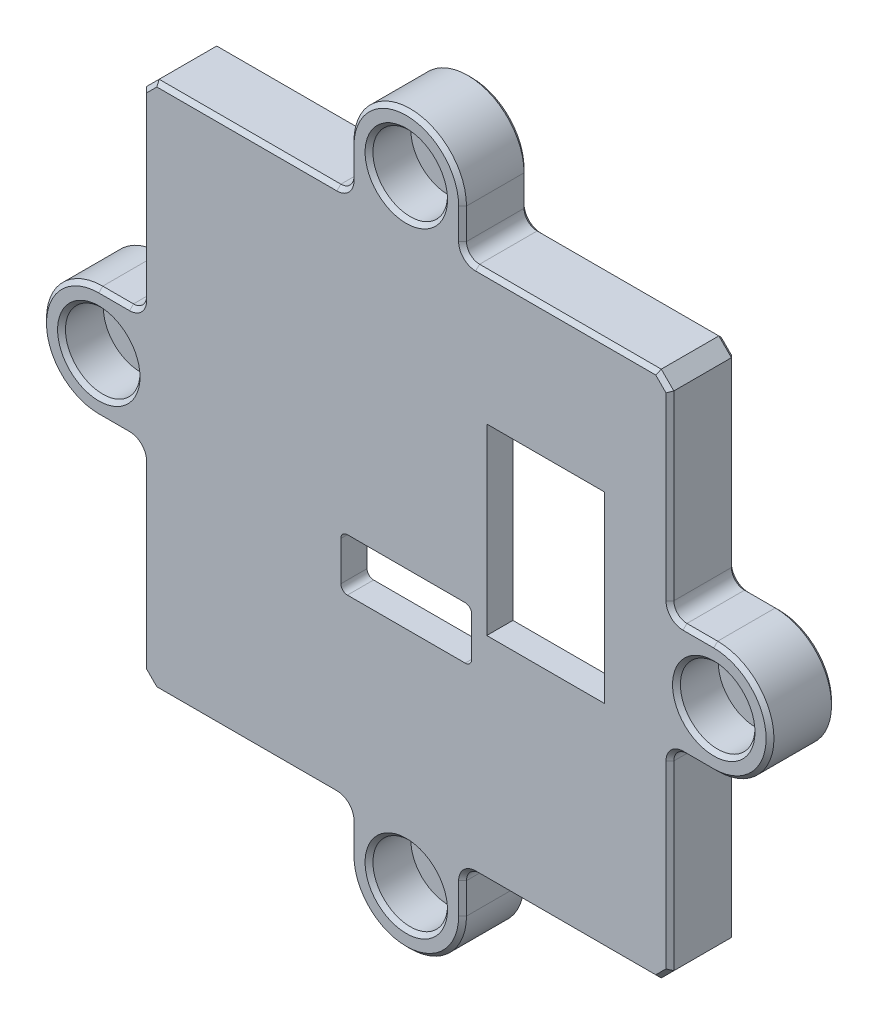
from build123d import *

# Parameters (mm, degrees)
SKETCH1_R           = 1.75
SKETCH1_W           = 9
SKETCH1_H           = 14
SKETCH1_W_2         = 10
SKETCH1_H_2         = 4
BOSS_EXTRUDE1_DEPTH = 5
FILLET3_R           = 0.5
SKETCH2_R           = 2.85
CUT_EXTRUDE1_DEPTH  = 3.2
SKETCH3_R           = 2.407181936
SKETCH3_R_2         = 2.340327513
SKETCH3_R_3         = 2.41187395
SKETCH3_R_4         = 2.413205516
BOSS_EXTRUDE2_DEPTH = 0.2
SKETCH4_W           = 35
SKETCH4_H           = 35
CUT_EXTRUDE2_DEPTH  = 4
SKETCH5_W           = 9
SKETCH5_H           = 14
BOSS_EXTRUDE3_DEPTH = 1
FILLET2_R           = 1
FILLET1_R           = 2
CHAMFER1_SIZE       = 0.3


with BuildPart() as part:
    # Sketch1 → Boss-Extrude1 (new body)
    with BuildSketch(Plane.XY):
        with BuildLine():
            Line((19.188334778, 20.15), (20.15, 19.188334778))
            Line((20.15, 19.188334778), (20.15, 4.3))
            Line((20.15, 4.3), (23.5, 4.3))
            ThreePointArc((23.5, 4.3), (27.8, 0), (23.5, -4.3))
            Line((23.5, -4.3), (20.15, -4.3))
            Line((20.15, -4.3), (20.15, -19.188334778))
            Line((20.15, -19.188334778), (19.188334778, -20.15))
            Line((19.188334778, -20.15), (4.3, -20.15))
            Line((4.3, -20.15), (4.3, -23.5))
            ThreePointArc((4.3, -23.5), (0, -27.8), (-4.3, -23.5))
            Line((-4.3, -23.5), (-4.3, -20.15))
            Line((-4.3, -20.15), (-19.188334778, -20.15))
            Line((-19.188334778, -20.15), (-20.15, -19.188334778))
            Line((-20.15, -19.188334778), (-20.15, -4.3))
            Line((-20.15, -4.3), (-23.5, -4.3))
            ThreePointArc((-23.5, -4.3), (-27.8, 0), (-23.5, 4.3))
            Line((-23.5, 4.3), (-20.15, 4.3))
            Line((-20.15, 4.3), (-20.15, 19.188334778))
            Line((-20.15, 19.188334778), (-19.188334778, 20.15))
            Line((-19.188334778, 20.15), (-4.3, 20.15))
            Line((-4.3, 20.15), (-4.3, 23.5))
            ThreePointArc((-4.3, 23.5), (0, 27.8), (4.3, 23.5))
            Line((4.3, 23.5), (4.3, 20.15))
            Line((4.3, 20.15), (19.188334778, 20.15))
        make_face()
        with Locations((0, 23.5)):
            Circle(SKETCH1_R, mode=Mode.SUBTRACT)
        with Locations((23.5, 0)):
            Circle(SKETCH1_R, mode=Mode.SUBTRACT)
        with Locations((0, -23.5)):
            Circle(SKETCH1_R, mode=Mode.SUBTRACT)
        with Locations((-23.5, 0)):
            Circle(SKETCH1_R, mode=Mode.SUBTRACT)
        with Locations((10.65, 3.15)):
            Rectangle(SKETCH1_W, SKETCH1_H, mode=Mode.SUBTRACT)
        with Locations((0, -4.5)):
            Rectangle(SKETCH1_W_2, SKETCH1_H_2, mode=Mode.SUBTRACT)
    extrude(amount=BOSS_EXTRUDE1_DEPTH)

    # Fillet3
    fillet3_edges = [part.edges().sort_by_distance(p)[0] for p in [
        (-5, -2.5, 2.5),
        (-5, -6.5, 2.5),
        (5, -6.5, 2.5),
        (5, -2.5, 2.5),
    ]]
    fillet(fillet3_edges, radius=FILLET3_R)

    # Sketch2 → Cut-Extrude1 (cut)
    with BuildSketch(Plane.XY.offset(5)):
        with Locations((0, 23.5)):
            Circle(SKETCH2_R)
        with Locations((23.5, 0)):
            Circle(SKETCH2_R)
        with Locations((-23.5, 0)):
            Circle(SKETCH2_R)
        with Locations((0, -23.5)):
            Circle(SKETCH2_R)
    extrude(amount=-CUT_EXTRUDE1_DEPTH, mode=Mode.SUBTRACT)

    # Sketch3 → Boss-Extrude2 (add)
    with BuildSketch(Plane.XY.offset(1.8)):
        with Locations((0, 23.5)):
            Circle(SKETCH3_R)
        with Locations((23.5, 0)):
            Circle(SKETCH3_R_2)
        with Locations((0, -23.5)):
            Circle(SKETCH3_R_3)
        with Locations((-23.5, 0)):
            Circle(SKETCH3_R_4)
    extrude(amount=-BOSS_EXTRUDE2_DEPTH)

    # Sketch4 → Cut-Extrude2 (cut)
    with BuildSketch(Plane(origin=(0, 0, 0), x_dir=(-1, 0, 0), z_dir=(0, 0, -1))):
        Rectangle(SKETCH4_W, SKETCH4_H)
    extrude(amount=-CUT_EXTRUDE2_DEPTH, mode=Mode.SUBTRACT)

    # Sketch5 → Boss-Extrude3 (add)
    with BuildSketch(Plane(origin=(0, 0, 4), x_dir=(-1, 0, 0), z_dir=(0, 0, -1))):
        Polygon((-16.15, 11.15), (-5.15, 11.15), (-5.15, -1.5), (6, -1.5), (6, -7.5), (-6, -7.5), (-6, -4.85), (-16.15, -4.85), align=None)
        with Locations((-10.65, 3.15)):
            Rectangle(SKETCH5_W, SKETCH5_H, mode=Mode.SUBTRACT)
        with BuildLine():
            Line((5, -3), (5, -6))
            ThreePointArc((5, -6), (4.853553391, -6.353553391), (4.5, -6.5))
            Line((4.5, -6.5), (-4.5, -6.5))
            ThreePointArc((-4.5, -6.5), (-4.853553391, -6.353553391), (-5, -6))
            Line((-5, -6), (-5, -3))
            ThreePointArc((-5, -3), (-4.853553391, -2.646446609), (-4.5, -2.5))
            Line((-4.5, -2.5), (4.5, -2.5))
            ThreePointArc((4.5, -2.5), (4.853553391, -2.646446609), (5, -3))
        make_face(mode=Mode.SUBTRACT)
    extrude(amount=BOSS_EXTRUDE3_DEPTH)

    # Fillet2
    fillet2_edges = [part.edges().sort_by_distance(p)[0] for p in [
        (20.15, 4.3, 2.5),
        (20.15, -4.3, 2.5),
        (4.3, -20.15, 2.5),
        (-4.3, -20.15, 2.5),
        (-20.15, -4.3, 2.5),
        (-20.15, 4.3, 2.5),
        (-4.3, 20.15, 2.5),
        (4.3, 20.15, 2.5),
    ]]
    fillet(fillet2_edges, radius=FILLET2_R)

    # Fillet1
    fillet1_edges = [part.edges().sort_by_distance(p)[0] for p in [
        (-17.5, 17.5, 2),
        (-17.5, -17.5, 2),
        (17.5, -17.5, 2),
        (17.5, 17.5, 2),
    ]]
    fillet(fillet1_edges, radius=FILLET1_R)

    # Chamfer1
    chamfer1_edges = [part.edges().sort_by_distance(p)[0] for p in [
        (0, 27.8, 5),
        (-2.85, 23.5, 5),
        (20.65, 0, 5),
        (-26.35, 0, 5),
        (-2.85, -23.5, 5),
        (-4.3, 22.325, 5),
        (19.669167389, 19.669167389, 0),
        (22.325, 4.3, 0),
        (27.8, 0, 0),
        (-19.669167389, 19.669167389, 5),
        (20.15, -12.244167389, 0),
        (19.669167389, -19.669167389, 0),
        (4.3, -22.325, 0),
        (0, -27.8, 0),
        (-12.244167389, -20.15, 0),
        (-19.669167389, -19.669167389, 0),
        (-22.325, -4.3, 0),
        (-20.15, 12.244167389, 5),
        (-27.8, 0, 0),
        (-20.15, -12.244167389, 0),
        (-20.15, -12.244167389, 5),
        (-22.325, 4.3, 0),
        (-22.325, 4.3, 5),
        (-20.15, 12.244167389, 0),
        (-12.244167389, 20.15, 0),
        (-12.244167389, 20.15, 5),
        (4.3, 22.325, 0),
        (-19.669167389, 19.669167389, 0),
        (4.3, 22.325, 5),
        (20.15, 12.244167389, 0),
        (20.15, 12.244167389, 5),
        (22.325, -4.3, 0),
        (22.325, -4.3, 5),
        (12.244167389, -20.15, 0),
        (12.244167389, -20.15, 5),
        (-4.3, 22.325, 0),
        (-4.3, -22.325, 0),
        (-4.3, -22.325, 5),
        (-20.442893219, -4.592893219, 0),
        (0, 27.8, 0),
        (-20.442893219, -4.592893219, 5),
        (-20.442893219, 4.592893219, 0),
        (-20.442893219, 4.592893219, 5),
        (-4.592893219, 20.442893219, 0),
        (-4.592893219, 20.442893219, 5),
        (4.592893219, 20.442893219, 0),
        (4.592893219, 20.442893219, 5),
        (20.442893219, 4.592893219, 0),
        (20.442893219, 4.592893219, 5),
        (20.442893219, -4.592893219, 0),
        (20.442893219, -4.592893219, 5),
        (4.592893219, -20.442893219, 0),
        (4.592893219, -20.442893219, 5),
        (-4.592893219, -20.442893219, 0),
        (-4.592893219, -20.442893219, 5),
        (12.244167389, 20.15, 0),
        (-17.5, 0, 0),
        (0, -17.5, 0),
        (17.5, 0, 0),
        (0, 17.5, 0),
        (-16.914213562, -16.914213562, 0),
        (16.914213562, -16.914213562, 0),
        (16.914213562, 16.914213562, 0),
        (-16.914213562, 16.914213562, 0),
        (-27.8, 0, 5),
        (-22.325, -4.3, 5),
        (-19.669167389, -19.669167389, 5),
        (12.244167389, 20.15, 5),
        (-12.244167389, -20.15, 5),
        (-1.75, 23.5, 0),
        (0, -27.8, 5),
        (21.75, 0, 0),
        (4.3, -22.325, 5),
        (-1.75, -23.5, 0),
        (-25.25, 0, 0),
        (19.669167389, -19.669167389, 5),
        (20.15, -12.244167389, 5),
        (27.8, 0, 5),
        (22.325, 4.3, 5),
        (19.669167389, 19.669167389, 5),
    ]]
    chamfer(chamfer1_edges, length=CHAMFER1_SIZE)


solid = part.part
